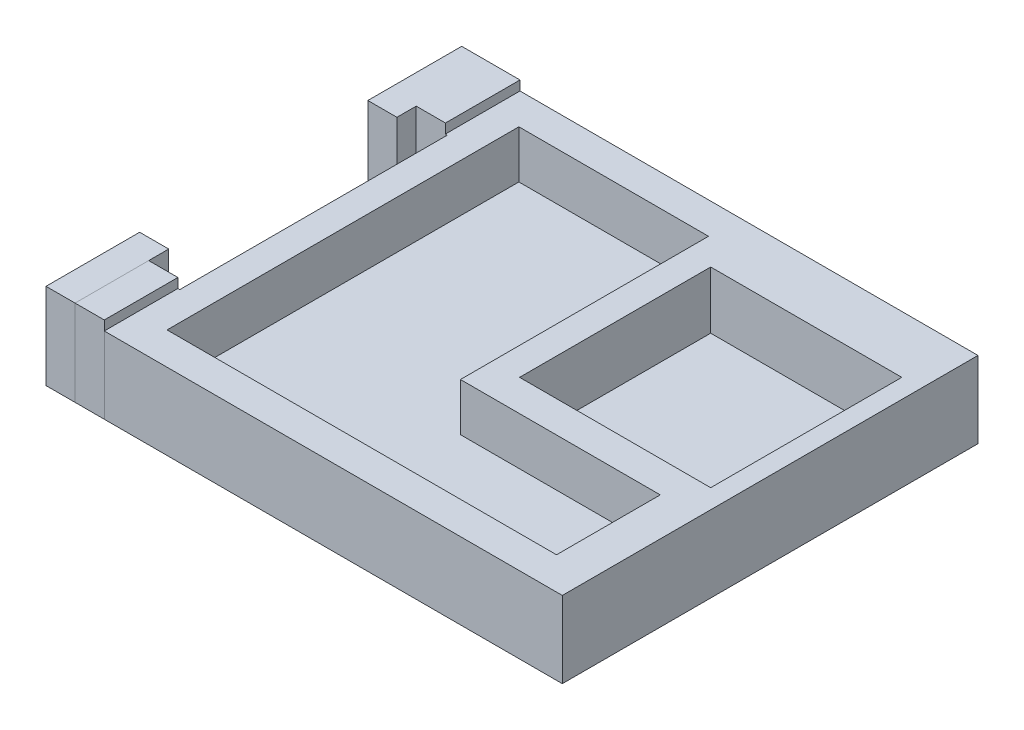
from build123d import *

# Parameters (mm, degrees)
SKETCH_1_W           = 47.7290867
SKETCH_1_H           = 43.5
EXTRUDE_1_DEPTH      = 2
SKETCH_1_4_W         = 47.7290867
SKETCH_1_4_H         = 43.5
SKETCH_1_4_W_2       = 20
SKETCH_1_4_H_2       = 20
EXTRUDE_2_DEPTH      = 6
SKETCH_6_W           = 3.057803049
SKETCH_6_H           = 7.702499636
EXTRUDE_5_DEPTH      = 1
EXTRUDE_5_DEPTH_BACK = 8
SKETCH_5_W           = 3.042196951
SKETCH_5_H           = 9
EXTRUDE_6_DEPTH      = 9.8
EXTRUDE_START        = -8
EXTRUDE_7_DEPTH      = 9
SKETCH_3_W           = 7.8
SKETCH_3_H           = 8
SKETCH_3_W_2         = 7.702499636
EXTRUDE_3_DEPTH      = 0.2
CUT_EXTRUDE_1_DEPTH  = 5


with BuildPart() as part:
    # Эскиз1 → Бобышка-Вытянуть1 (new body)
    with BuildSketch(Plane(origin=(0, 0, 0), x_dir=(1, 0, 0), z_dir=(0, 1, 0))):
        with Locations((-24.749678485, 9.965878375)):
            Rectangle(SKETCH_1_W, SKETCH_1_H)
    extrude(amount=-EXTRUDE_1_DEPTH)

    # Эскиз1<4> → Бобышка-Вытянуть2 (add)
    with BuildSketch(Plane(origin=(0, 0, 0), x_dir=(1, 0, 0), z_dir=(0, 1, 0))):
        with Locations((-24.749678485, 9.965878375)):
            Rectangle(SKETCH_1_4_W, SKETCH_1_4_H)
        with Locations((-12.885135135, 15.743243243)):
            Rectangle(SKETCH_1_4_W_2, SKETCH_1_4_H_2, mode=Mode.SUBTRACT)
    extrude(amount=EXTRUDE_2_DEPTH)

    # Эскиз3 → Бобышка-Вытянуть3 (add)
    with BuildSketch(Plane.ZY.offset(48.614221835)):
        with Locations((-27.815878375, 2)):
            Rectangle(SKETCH_3_W, SKETCH_3_H)
        with Locations((7.932871807, 2)):
            Rectangle(SKETCH_3_W_2, SKETCH_3_H)
    extrude(amount=EXTRUDE_3_DEPTH)

    # Эскиз8 → Вырез-Вытянуть1 (cut)
    with BuildSketch(Plane(origin=(0, 6, 0), x_dir=(1, 0, 0), z_dir=(0, 1, 0))):
        Polygon((-45.627384995, 28.412635597), (-25.782809099, 28.412635597), (-25.782809099, 2.453305659), (-4.872082547, 2.453305659), (-4.872082547, -8.403340898), (-25.782809099, -8.403340898), (-45.627384995, -8.403340898), align=None)
    extrude(amount=-CUT_EXTRUDE_1_DEPTH, mode=Mode.SUBTRACT)


with BuildPart() as body_2:
    # Эскиз6 → Бобышка-Вытянуть5 (new body, two sides)
    with BuildSketch(Plane(origin=(0, 6, 0), x_dir=(1, 0, 0), z_dir=(0, 1, 0))) as extrude_5_sk:
        with Locations((-50.34312336, -7.932871807)):
            Rectangle(SKETCH_6_W, SKETCH_6_H)
    extrude(amount=EXTRUDE_5_DEPTH)
    extrude(extrude_5_sk.sketch, amount=-EXTRUDE_5_DEPTH_BACK)


with BuildPart() as body_3:
    # Эскиз5 → Бобышка-Вытянуть6 (new body)
    with BuildSketch(Plane.XY.offset(11.784121625)):
        with Locations((-53.39312336, 2.5)):
            Rectangle(SKETCH_5_W, SKETCH_5_H)
    extrude(amount=-EXTRUDE_6_DEPTH)


with BuildPart() as body_4:
    # Эскиз7 → Бобышка-Вытянуть7 (new body)
    with BuildSketch(Plane(origin=(0, 6, 0), x_dir=(1, 0, 0), z_dir=(0, 1, 0)).offset(EXTRUDE_START)):
        Polygon((-54.914221835, 31.715878375), (-48.814221835, 31.715878375), (-48.814221835, 23.915878375), (-51.872024884, 23.915878375), (-51.872024884, 21.895746715), (-54.914221835, 21.895746715), (-54.914221835, 23.915878375), align=None)
    extrude(amount=EXTRUDE_7_DEPTH)


solid = Compound([part.part, body_2.part, body_3.part, body_4.part])
